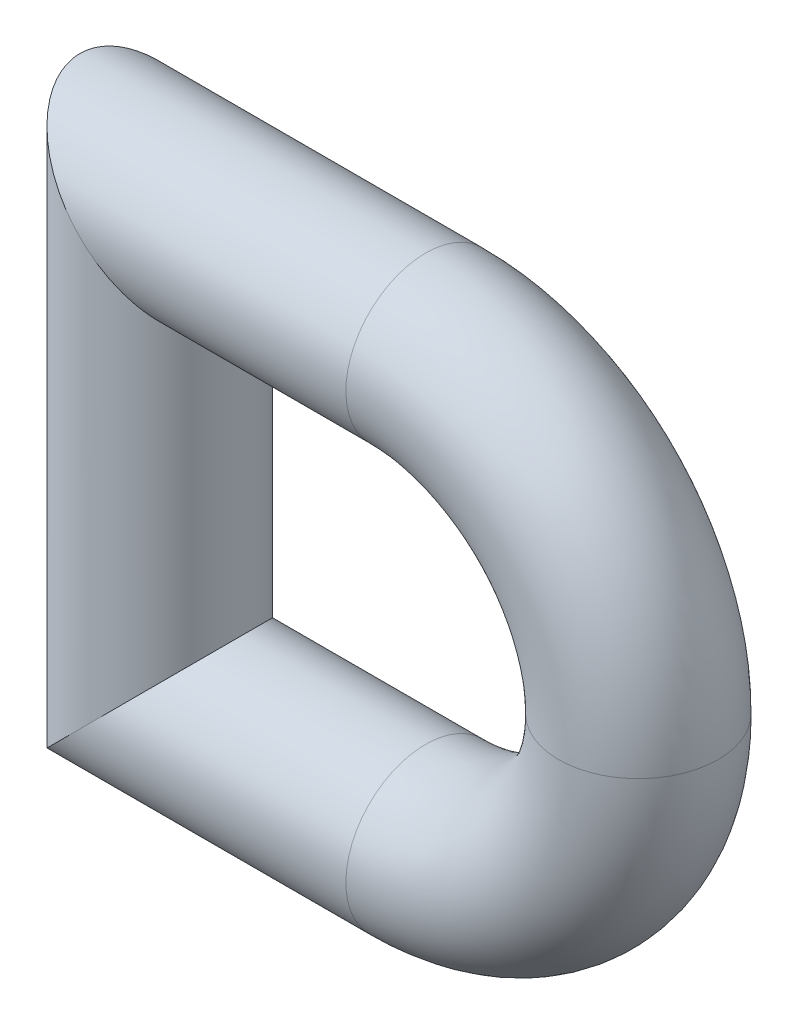
from build123d import *

# Parameters (mm, degrees)
SKETCH2_R = 3


with BuildPart() as part:
    # Sweep1: sweep along a path in Sketch1
    with BuildLine(Plane.XY) as sweep1_path:
        Line((0, -8), (0, 8))
        Line((0, 8), (10, 8))
        ThreePointArc((10, 8), (18, 0), (10, -8))
        Line((10, -8), (0, -8))
    # Sketch2 → Sweep1 (sweep)
    with BuildSketch(Plane(origin=(0, 0, 0), x_dir=(1, 0, 0), z_dir=(0, 1, 0))):
        with Locations((18, 0)):
            Circle(SKETCH2_R)
    sweep(path=sweep1_path.line, transition=Transition.RIGHT)


solid = part.part
